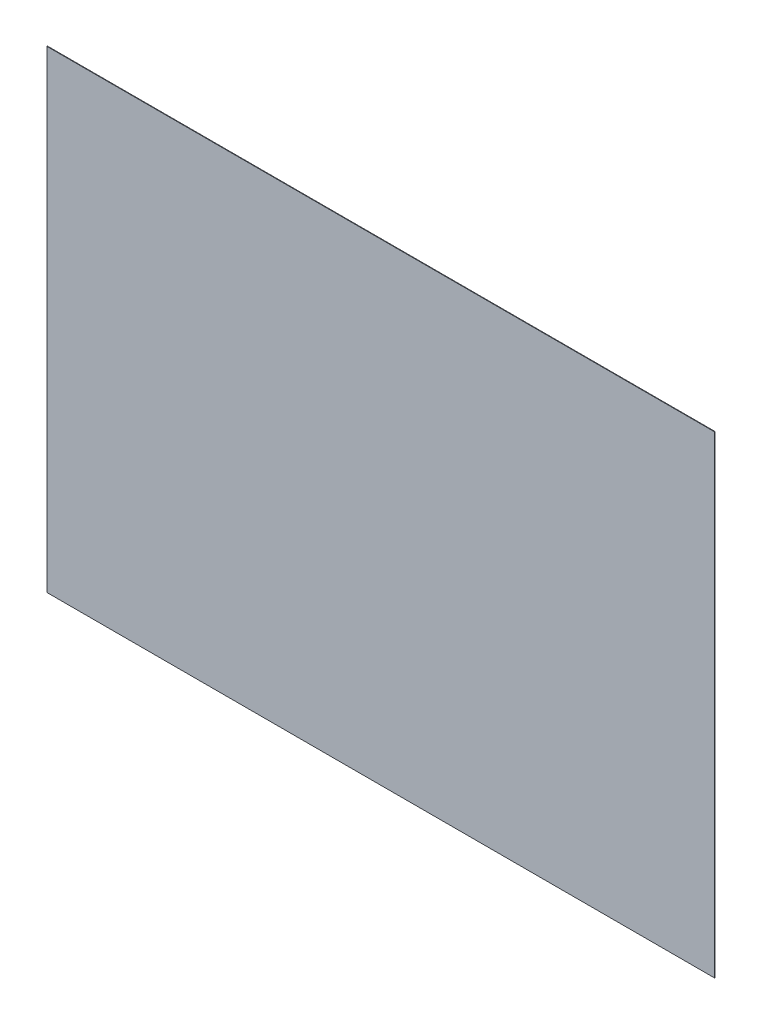
from build123d import *

# Parameters (mm, degrees)
SKETCH1_W           = 609.6
SKETCH1_H           = 431.8
BOSS_EXTRUDE1_DEPTH = 0.5


with BuildPart() as part:
    # Sketch1 → Boss-Extrude1 (new body)
    with BuildSketch(Plane.XY):
        Rectangle(SKETCH1_W, SKETCH1_H)
    extrude(amount=BOSS_EXTRUDE1_DEPTH)


solid = part.part
